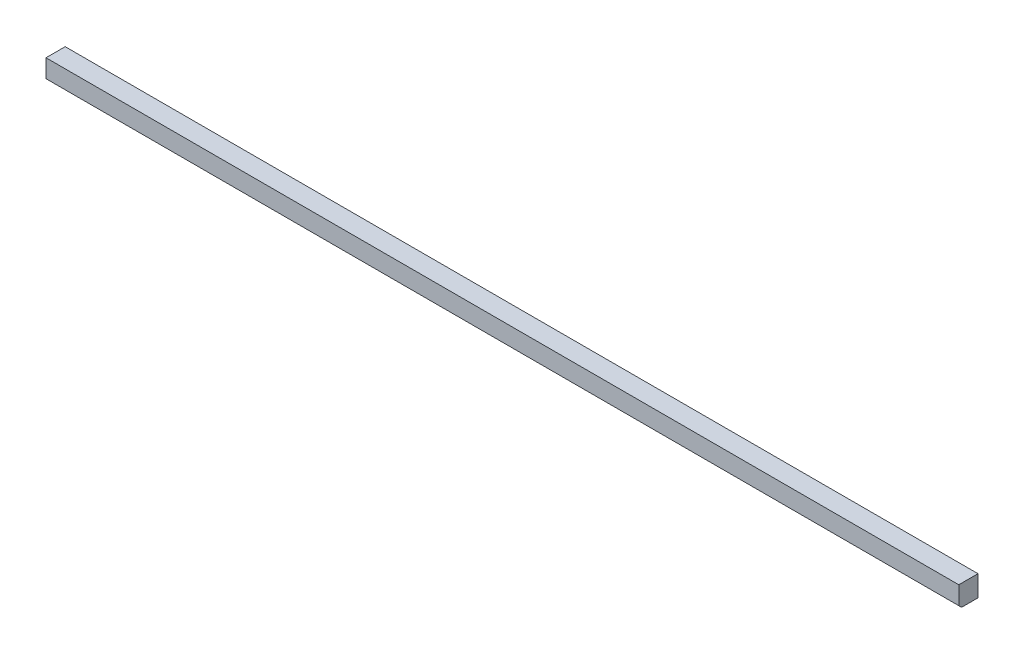
from build123d import *

# Parameters (mm, degrees)
SKETCH1_W           = 830.2752
SKETCH1_H           = 17.4625
BOSS_EXTRUDE1_DEPTH = 19.05
CHAMFER1_SIZE       = 2.54


with BuildPart() as part:
    # Sketch1 → Boss-Extrude1 (new body)
    with BuildSketch(Plane(origin=(0, 0, 0), x_dir=(1, 0, 0), z_dir=(0, 1, 0))):
        with Locations((415.1376, 8.73125)):
            Rectangle(SKETCH1_W, SKETCH1_H)
    extrude(amount=BOSS_EXTRUDE1_DEPTH)

    # Chamfer1
    chamfer1_edges = [part.edges().sort_by_distance(p)[0] for p in [
        (415.1376, 0, 0),
    ]]
    chamfer(chamfer1_edges, length=CHAMFER1_SIZE)


solid = part.part
